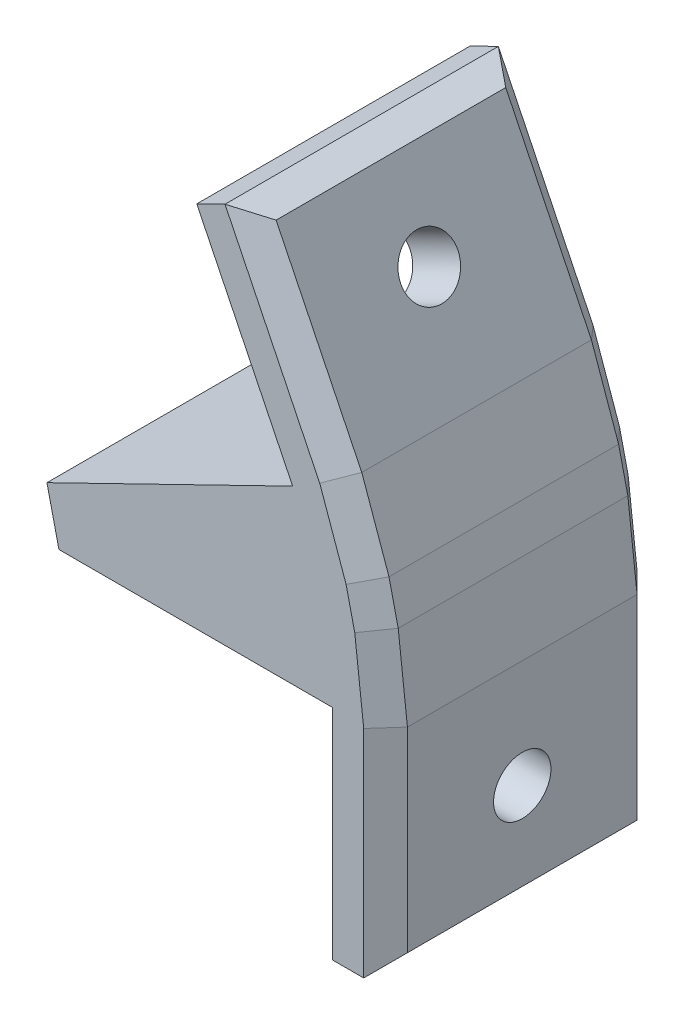
from build123d import *

# Parameters (mm, degrees)
BOSS_EXTRU_1_DEPTH      = 20
ESQUISSE2_W             = 20
ESQUISSE2_H             = 20
BOSS_EXTRU_2_DEPTH      = 2
ESQUISSE3_W             = 20
ESQUISSE3_H             = 20
BOSS_EXTRU_3_DEPTH      = 2
ESQUISSE4_W             = 20
ESQUISSE4_H             = 8.998042174
BOSS_EXTRU_4_DEPTH      = 4
BOSS_EXTRU_5_DEPTH      = 20
CHANFREIN1_SIZE         = 3
CHANFREIN2_SIZE         = 1.6
ESQUISSE7_R             = 2.1
ENL_V_MAT_EXTRU_1_DEPTH = 13.855900094
ESQUISSE8_R             = 2.1
ENL_V_MAT_EXTRU_2_DEPTH = 4.897480259
BOSS_EXTRU_6_DEPTH      = 20


with BuildPart() as part:
    # Esquisse1 → Boss.-Extru.1 (new body)
    with BuildSketch(Plane.XY):
        Polygon((0, 0), (20, 0), (17.975880926, 8.767422936), align=None)
    extrude(amount=BOSS_EXTRU_1_DEPTH)

    # Esquisse2 → Boss.-Extru.2 (add)
    with BuildSketch(Plane(origin=(0, 0, 0), x_dir=(0.898794046, 0.438371147, 0), z_dir=(-0.438371147, 0.898794046, 0))):
        with Locations((10, -10)):
            Rectangle(ESQUISSE2_W, ESQUISSE2_H)
    extrude(amount=BOSS_EXTRU_2_DEPTH)

    # Esquisse3 → Boss.-Extru.3 (add)
    with BuildSketch(Plane.XZ):
        with Locations((10, 10)):
            Rectangle(ESQUISSE3_W, ESQUISSE3_H)
    extrude(amount=BOSS_EXTRU_3_DEPTH)

    # Esquisse4 → Boss.-Extru.4 (add)
    with BuildSketch(Plane(origin=(18.987940463, 4.383711468, 0), x_dir=(0, 0, -1), z_dir=(0.974370065, 0.224951054, 0))):
        with Locations((-10, 0)):
            Rectangle(ESQUISSE4_W, ESQUISSE4_H)
    extrude(amount=BOSS_EXTRU_4_DEPTH)

    # Esquisse5 → Boss.-Extru.5 (add)
    with BuildSketch(Plane.XY.offset(20)):
        Polygon((17.099138632, 10.565011028), (10.085200284, 24.945715769), (13.588232336, 26.65425866), (21.873361185, 9.667227153), (17.975880926, 8.767422936), align=None)
        Polygon((20, 0), (20, -2), (20, -18), (23.897480259, -18), (23.897480259, 0.899804217), align=None)
    extrude(amount=-BOSS_EXTRU_5_DEPTH)

    # Chanfrein1
    chanfrein1_edges = [part.edges().sort_by_distance(p)[0] for p in [
        (23.897480259, 0.899804217, 10),
        (21.873361185, 9.667227153, 10),
    ]]
    chamfer(chanfrein1_edges, length=CHANFREIN1_SIZE)

    # Chanfrein2
    chanfrein2_edges = [part.edges().sort_by_distance(p)[0] for p in [
        (13.588232336, 26.65425866, 10),
        (23.897480259, -10.050097891, 0),
        (23.897480259, -18, 10),
        (23.897480259, -10.050097891, 20),
        (22.885420722, 5.283515685, 20),
        (22.885420722, 5.283515685, 0),
        (17.073240041, 19.508933976, 0),
        (21.553231046, 9.553863125, 0),
        (23.560053678, 0.861359315, 0),
        (17.073240041, 19.508933976, 20),
        (21.553231046, 9.553863125, 20),
        (23.560053678, 0.861359315, 20),
    ]]
    chamfer(chanfrein2_edges, length=CHANFREIN2_SIZE)

    # Esquisse7 → Enlèv. mat.-Extru.1 (cut, through all)
    with BuildSketch(Plane(origin=(17.975880926, 8.767422936, 0), x_dir=(0, 0, 1), z_dir=(-0.898794046, -0.438371147, 0))):
        with Locations((10, 10)):
            Circle(ESQUISSE7_R)
    extrude(amount=-ENL_V_MAT_EXTRU_1_DEPTH, mode=Mode.SUBTRACT)

    # Esquisse8 → Enlèv. mat.-Extru.2 (cut, through all)
    with BuildSketch(Plane.ZY.offset(-20)):
        with Locations((10, -10)):
            Circle(ESQUISSE8_R)
    extrude(amount=-ENL_V_MAT_EXTRU_2_DEPTH, mode=Mode.SUBTRACT)

    # Esquisse9 → Boss.-Extru.6 (add)
    with BuildSketch(Plane.XY.offset(20)):
        Polygon((-0.876742294, 1.797588093), (0, 0), (0, -2), align=None)
    extrude(amount=-BOSS_EXTRU_6_DEPTH)


solid = part.part
